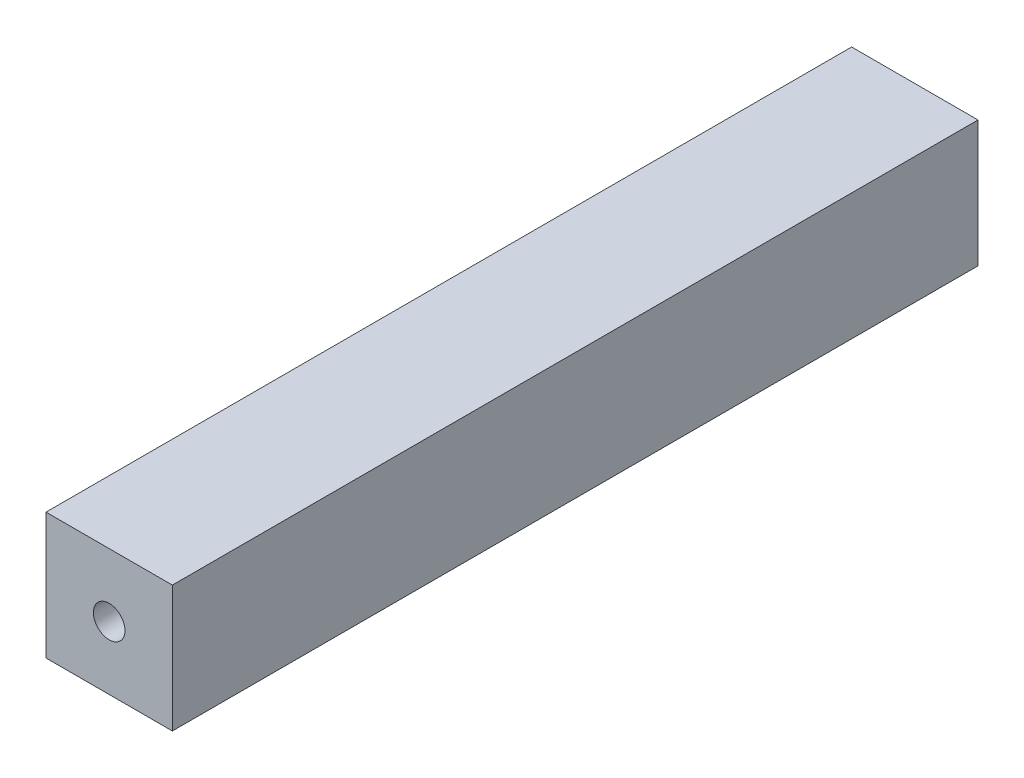
from build123d import *

# Parameters (mm, degrees)
SKETCH1_W           = 40
SKETCH1_H           = 40
SKETCH1_R           = 5
BOSS_EXTRUDE1_DEPTH = 255


with BuildPart() as part:
    # Sketch1 → Boss-Extrude1 (new body)
    with BuildSketch(Plane.XY):
        with Locations((536, -209)):
            Rectangle(SKETCH1_W, SKETCH1_H)
        with Locations((536, -209)):
            Circle(SKETCH1_R, mode=Mode.SUBTRACT)
    extrude(amount=-BOSS_EXTRUDE1_DEPTH)


solid = part.part
